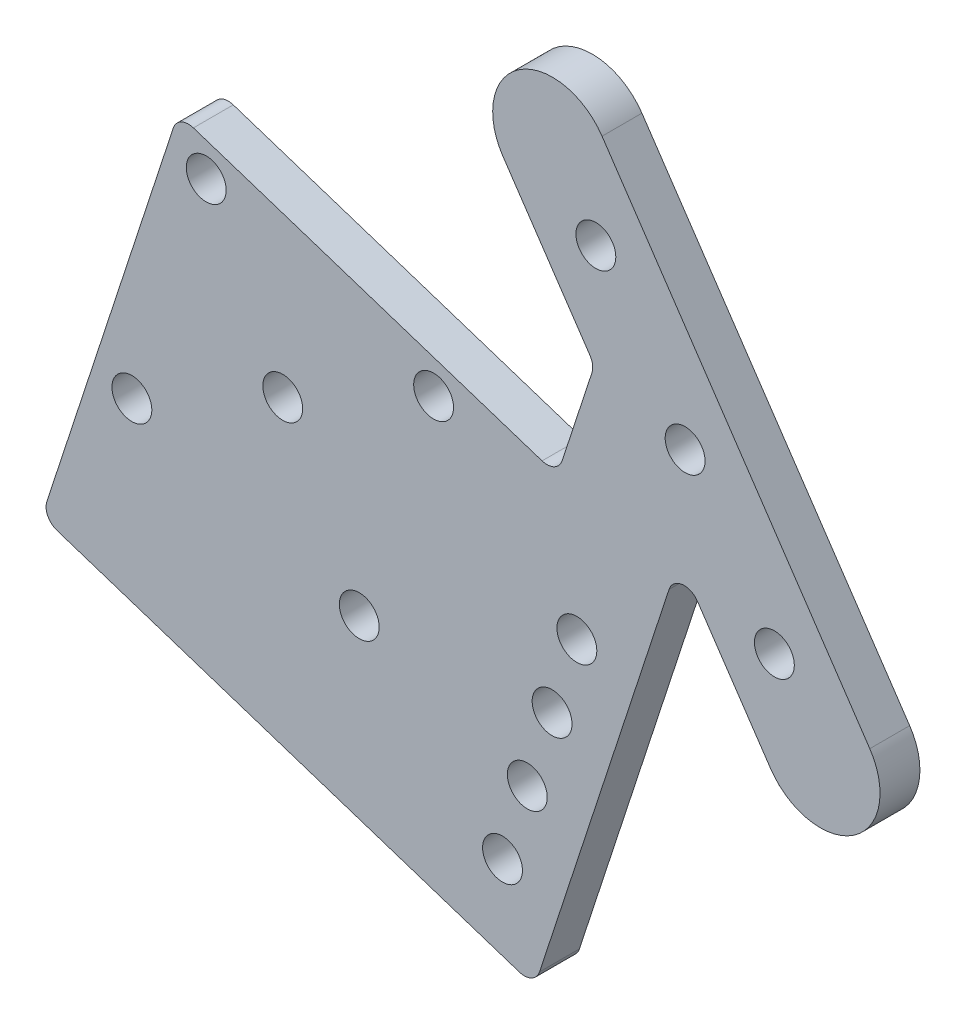
from build123d import *

# Parameters (mm, degrees)
SKETCH1_R           = 3.175
BOSS_EXTRUDE2_DEPTH = 6.35
BOSS_EXTRUDE3_DEPTH = 6.35
SKETCH3_R           = 3.175
CUT_EXTRUDE1_DEPTH  = 6.35
FILLET1_R           = 2.54


with BuildPart() as part:
    # Sketch1 → Boss-Extrude2 (new body)
    with BuildSketch(Plane.XY):
        with BuildLine():
            Line((-13.229381943, 36.614978912), (29.410930021, -26.537564946))
            ThreePointArc((29.410930021, -26.537564946), (26.846901034, -39.761671923), (13.622794056, -37.197642936))
            Line((13.622794056, -37.197642936), (-0.945979198, -15.620523785))
            Line((-0.945979198, -15.620523785), (-23.975246761, -86.039905978))
            Line((-23.975246761, -86.039905978), (-42.081609524, -80.118577791))
            Line((-42.081609524, -80.118577791), (-14.448744653, 4.37778177))
            Line((-14.448744653, 4.37778177), (-29.017517907, 25.954900921))
            ThreePointArc((-29.017517907, 25.954900921), (-26.45348892, 39.179007899), (-13.229381943, 36.614978912))
        make_face()
        with Locations((-14.213437321, 21.050847952)):
            Circle(SKETCH1_R, mode=Mode.SUBTRACT)
        with Locations((14.213437321, -21.050847952)):
            Circle(SKETCH1_R, mode=Mode.SUBTRACT)
        Circle(SKETCH1_R, mode=Mode.SUBTRACT)
        with Locations((-29.080876018, -71.008333376)):
            Circle(SKETCH1_R, mode=Mode.SUBTRACT)
        with Locations((-25.133323893, -58.937424867)):
            Circle(SKETCH1_R, mode=Mode.SUBTRACT)
        with Locations((-21.185771769, -46.866516358)):
            Circle(SKETCH1_R, mode=Mode.SUBTRACT)
        with Locations((-17.238219645, -34.79560785)):
            Circle(SKETCH1_R, mode=Mode.SUBTRACT)
    extrude(amount=BOSS_EXTRUDE2_DEPTH)

    # Sketch2 → Boss-Extrude3 (add)
    with BuildSketch(Plane(origin=(0, 0, 0), x_dir=(-1, 0, 0), z_dir=(0, 0, -1))):
        Polygon((20.370072839, -13.728580993), (42.081609524, -80.118577791), (102.436152067, -60.380817169), (80.724615383, 6.009179629), align=None)
    extrude(amount=-BOSS_EXTRUDE3_DEPTH)

    # Sketch3 → Cut-Extrude1 (cut)
    with BuildSketch(Plane(origin=(0, 0, 0), x_dir=(-1, 0, 0), z_dir=(0, 0, -1))):
        with Locations((76.268181978, -0.792959837)):
            Circle(SKETCH3_R)
        with Locations((40.055456452, -12.63561621)):
            Circle(SKETCH3_R)
        with Locations((51.898112825, -48.848341736)):
            Circle(SKETCH3_R)
        with Locations((88.110838352, -37.005685363)):
            Circle(SKETCH3_R)
        with Locations((64.083147402, -24.820650786)):
            Circle(SKETCH3_R)
    extrude(amount=-CUT_EXTRUDE1_DEPTH, mode=Mode.SUBTRACT)

    # Fillet1
    fillet1_edges = [part.edges().sort_by_distance(p)[0] for p in [
        (-0.945979198, -15.620523785, 3.175),
        (-23.975246761, -86.039905978, 3.175),
        (-14.448744653, 4.37778177, 3.175),
        (-20.370072839, -13.728580993, 3.175),
        (-80.724615383, 6.009179629, 3.175),
        (-102.436152067, -60.380817169, 3.175),
    ]]
    fillet(fillet1_edges, radius=FILLET1_R)


solid = part.part
